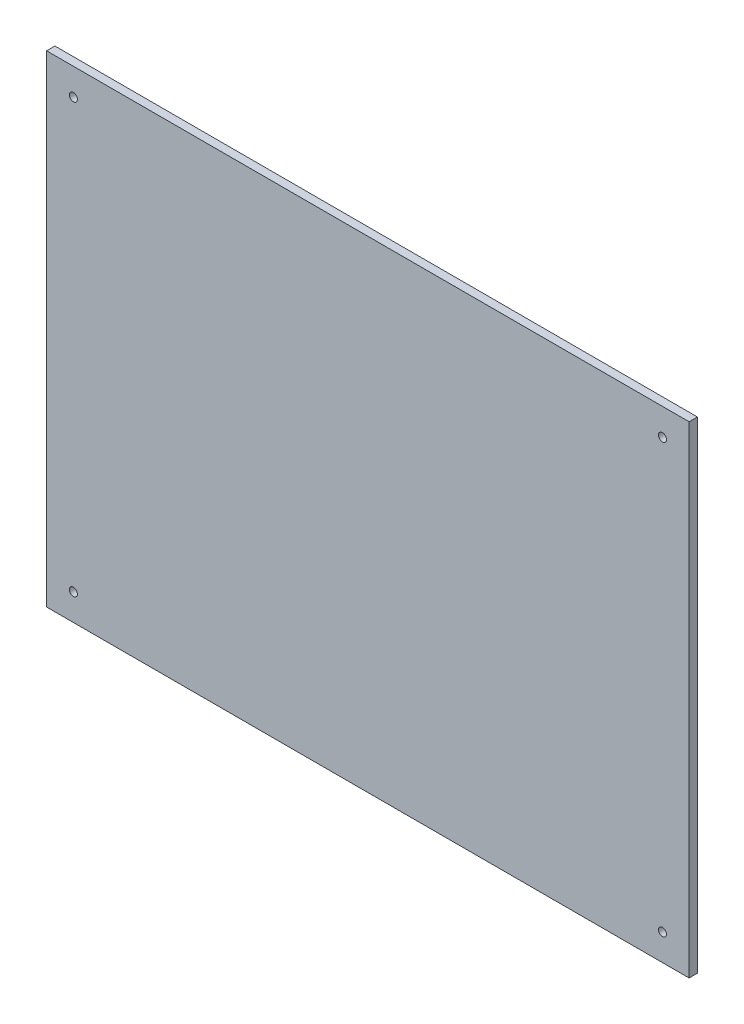
from build123d import *

# Parameters (mm, degrees)
SKETCH1_W           = 121.9
SKETCH1_H           = 91.4
SKETCH1_R           = 0.762
BOSS_EXTRUDE1_DEPTH = 1.5748


with BuildPart() as part:
    # Sketch1 → Boss-Extrude1 (new body)
    with BuildSketch(Plane.XY):
        Rectangle(SKETCH1_W, SKETCH1_H)
        with Locations((-55.87, 40.62)):
            Circle(SKETCH1_R, mode=Mode.SUBTRACT)
        with Locations((55.89, 40.62)):
            Circle(SKETCH1_R, mode=Mode.SUBTRACT)
        with Locations((55.89, -40.66)):
            Circle(SKETCH1_R, mode=Mode.SUBTRACT)
        with Locations((-55.87, -40.66)):
            Circle(SKETCH1_R, mode=Mode.SUBTRACT)
    extrude(amount=BOSS_EXTRUDE1_DEPTH)


solid = part.part
